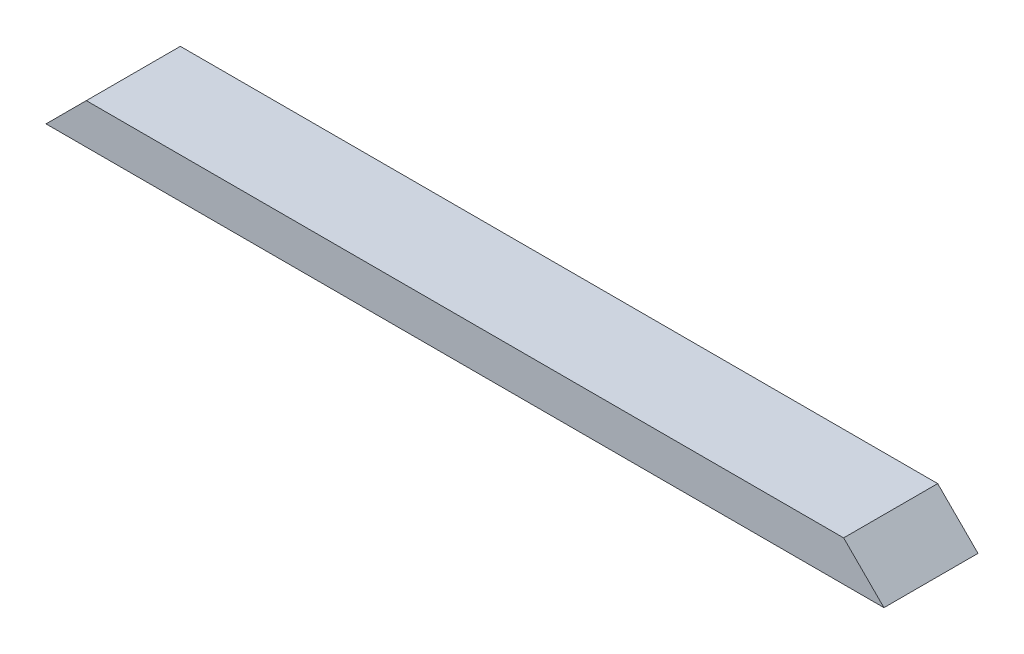
from build123d import *

# Parameters (mm, degrees)
SKETCH1_W           = 792.1752
SKETCH1_H           = 88.9
BOSS_EXTRUDE1_DEPTH = 38.1
CUT_EXTRUDE1_DEPTH  = 89.9


with BuildPart() as part:
    # Sketch1 → Boss-Extrude1 (new body)
    with BuildSketch(Plane(origin=(0, 0, 0), x_dir=(1, 0, 0), z_dir=(0, 1, 0))):
        with Locations((396.0876, 44.45)):
            Rectangle(SKETCH1_W, SKETCH1_H)
    extrude(amount=BOSS_EXTRUDE1_DEPTH)

    # Sketch2 → Cut-Extrude1 (cut, through all)
    with BuildSketch(Plane.XY):
        Polygon((0, 0), (38.1, 38.1), (0, 38.1), align=None)
        Polygon((792.1752, 0), (792.1752, 38.1), (754.0752, 38.1), align=None)
    extrude(amount=-CUT_EXTRUDE1_DEPTH, mode=Mode.SUBTRACT)


solid = part.part
